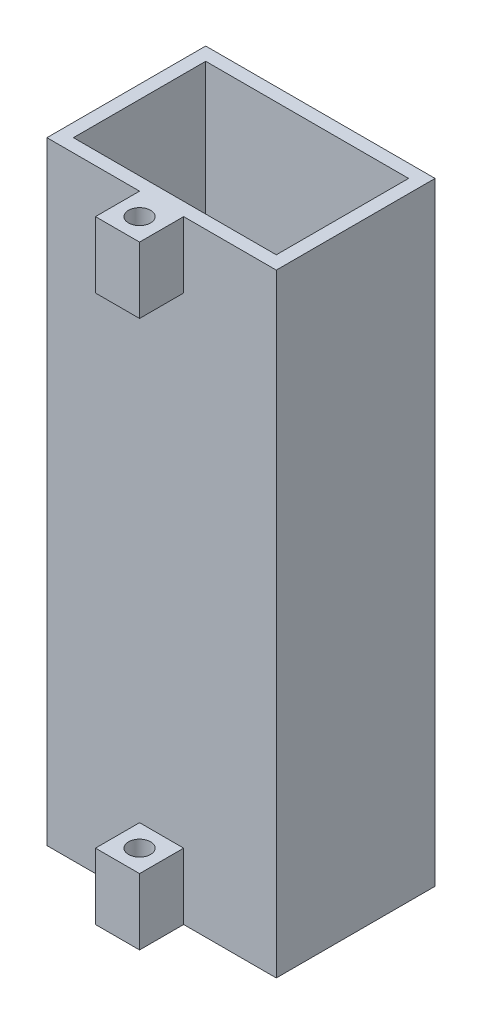
from build123d import *

# Parameters (mm, degrees)
SKETCH1_W               = 52
SKETCH1_H               = 36
BOSS_EXTRUDE1_DEPTH     = 3
BOSS_EXTRUDE2_START     = 3
SKETCH1_3_W             = 52
SKETCH1_3_H             = 36
SKETCH1_3_W_2           = 46
SKETCH1_3_H_2           = 30
BOSS_EXTRUDE2_DEPTH     = 136
SKETCH2_W               = 10
SKETCH2_H               = 15
BOSS_EXTRUDE3_DEPTH     = 10
SKETCH3_R               = 2.5
CUT_EXTRUDE1_DEPTH      = 1
CUT_EXTRUDE1_DEPTH_BACK = 140


with BuildPart() as part:
    # Sketch1 → Boss-Extrude1 (new body)
    with BuildSketch(Plane(origin=(0, 0, 0), x_dir=(1, 0, 0), z_dir=(0, 1, 0))):
        Rectangle(SKETCH1_W, SKETCH1_H)
    extrude(amount=BOSS_EXTRUDE1_DEPTH)

    # Sketch1_3 → Boss-Extrude2 (add)
    with BuildSketch(Plane(origin=(0, 0, 0), x_dir=(1, 0, 0), z_dir=(0, 1, 0)).offset(BOSS_EXTRUDE2_START)):
        Rectangle(SKETCH1_3_W, SKETCH1_3_H)
        Rectangle(SKETCH1_3_W_2, SKETCH1_3_H_2, mode=Mode.SUBTRACT)
    extrude(amount=BOSS_EXTRUDE2_DEPTH)

    # Sketch2 → Boss-Extrude3 (add)
    with BuildSketch(Plane.XY.offset(18)):
        with Locations((0, 131.5)):
            Rectangle(SKETCH2_W, SKETCH2_H)
        with Locations((0, 7.5)):
            Rectangle(SKETCH2_W, SKETCH2_H)
    extrude(amount=BOSS_EXTRUDE3_DEPTH)

    # Sketch3 → Cut-Extrude1 (cut, two sides)
    with BuildSketch(Plane(origin=(0, 139, 0), x_dir=(1, 0, 0), z_dir=(0, 1, 0))) as cut_extrude1_sk:
        with Locations((0, -23)):
            Circle(SKETCH3_R)
    extrude(amount=CUT_EXTRUDE1_DEPTH, mode=Mode.SUBTRACT)
    extrude(cut_extrude1_sk.sketch, amount=-CUT_EXTRUDE1_DEPTH_BACK, mode=Mode.SUBTRACT)


solid = part.part
